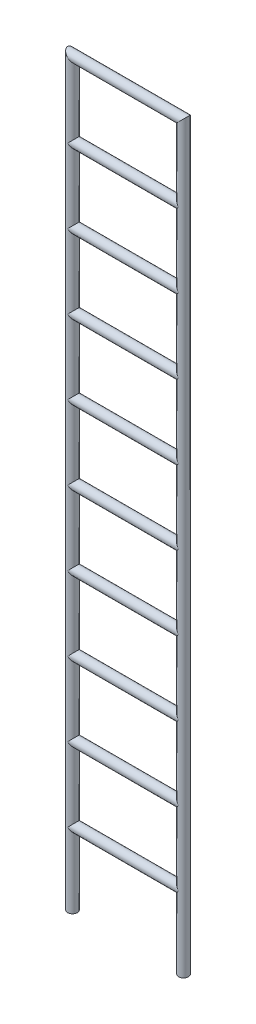
from build123d import *

# Parameters (mm, degrees)
SWEEP1_PROFILE_R = 20
LPATTERN1_COUNT  = 10
LPATTERN1_PITCH  = 304.8


with BuildPart() as part:
    # Sweep1: sweep along a path in Sketch3
    with BuildLine(Plane.XY) as sweep1_path:
        Line((0, 0), (0, 304.8))
        Line((0, 304.8), (457.2, 304.8))
        Line((457.2, 304.8), (457.2, 0))
    # Sweep1 profile (on start of the path) → Sweep1 (sweep)
    with BuildSketch(Plane.ZX):
        Circle(SWEEP1_PROFILE_R)
    sweep1 = sweep(path=sweep1_path.line, transition=Transition.RIGHT)

    # LPattern1: Sweep1 ×10
    with Locations(*[(0, i * LPATTERN1_PITCH, 0) for i in range(1, LPATTERN1_COUNT)]):
        add(sweep1)


solid = part.part
